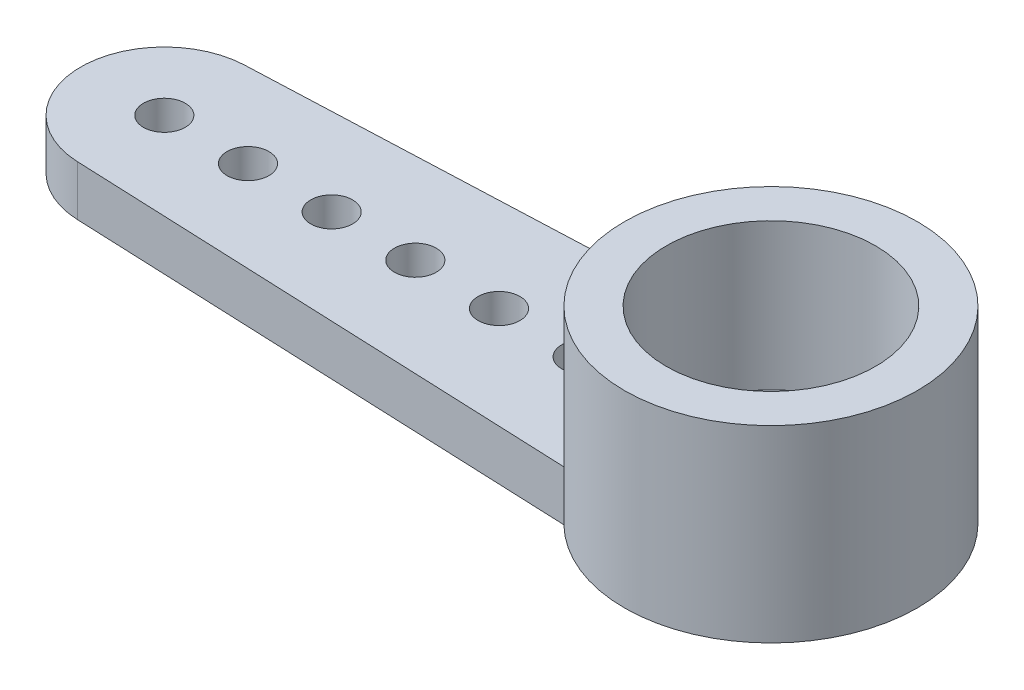
from build123d import *

# Parameters (mm, degrees)
SKETCH_1_R          = 0.5
EXTRUDE_1_DEPTH     = 1.2
SKETCH_1_3_R        = 3.5
SKETCH_1_3_R_2      = 2.5
EXTRUDE_2_DEPTH     = 4.5
SKETCH_1_4_R        = 2.5
EXTRUDE_3_DEPTH     = 1
SKETCH_3_R          = 1.25
CUT_EXTRUDE_1_DEPTH = 1


with BuildPart() as part:
    # 草图1 → 凸台-拉伸1 (new body)
    with BuildSketch(Plane(origin=(0, 0, 0), x_dir=(1, 0, 0), z_dir=(0, 1, 0))):
        with BuildLine():
            Line((4.682566803, 2.501585477), (-7.452442074, 1.998282013))
            ThreePointArc((-7.452442074, 1.998282013), (-9.369562674, 0), (-7.452442074, -1.998282013))
            Line((-7.452442074, -1.998282013), (4.682566803, -2.501585477))
            ThreePointArc((4.682566803, -2.501585477), (3.630437326, 0), (4.682566803, 2.501585477))
        make_face()
        with Locations((2.630437326, 0)):
            Circle(SKETCH_1_R, mode=Mode.SUBTRACT)
        with Locations((0.630437326, 0)):
            Circle(SKETCH_1_R, mode=Mode.SUBTRACT)
        with Locations((-1.369562674, 0)):
            Circle(SKETCH_1_R, mode=Mode.SUBTRACT)
        with Locations((-3.369562674, 0)):
            Circle(SKETCH_1_R, mode=Mode.SUBTRACT)
        with Locations((-5.369562674, 0)):
            Circle(SKETCH_1_R, mode=Mode.SUBTRACT)
        with Locations((-7.369562674, 0)):
            Circle(SKETCH_1_R, mode=Mode.SUBTRACT)
    extrude(amount=EXTRUDE_1_DEPTH)

    # 草图1<3> → 凸台-拉伸2 (add)
    with BuildSketch(Plane(origin=(0, 0, 0), x_dir=(1, 0, 0), z_dir=(0, 1, 0))):
        with Locations((7.130437326, 0)):
            Circle(SKETCH_1_3_R)
        with Locations((7.130437326, 0)):
            Circle(SKETCH_1_3_R_2, mode=Mode.SUBTRACT)
    extrude(amount=EXTRUDE_2_DEPTH)

    # 草图1<4> → 凸台-拉伸3 (add)
    with BuildSketch(Plane(origin=(0, 0, 0), x_dir=(1, 0, 0), z_dir=(0, 1, 0))):
        with Locations((7.130437326, 0)):
            Circle(SKETCH_1_4_R)
    extrude(amount=EXTRUDE_3_DEPTH)

    # 草图3 → 切除-拉伸1 (cut)
    with BuildSketch(Plane(origin=(0, 0, 0), x_dir=(1, 0, 0), z_dir=(0, 1, 0))):
        with Locations((7.130437326, 0)):
            Circle(SKETCH_3_R)
    extrude(amount=CUT_EXTRUDE_1_DEPTH, mode=Mode.SUBTRACT)


solid = part.part
